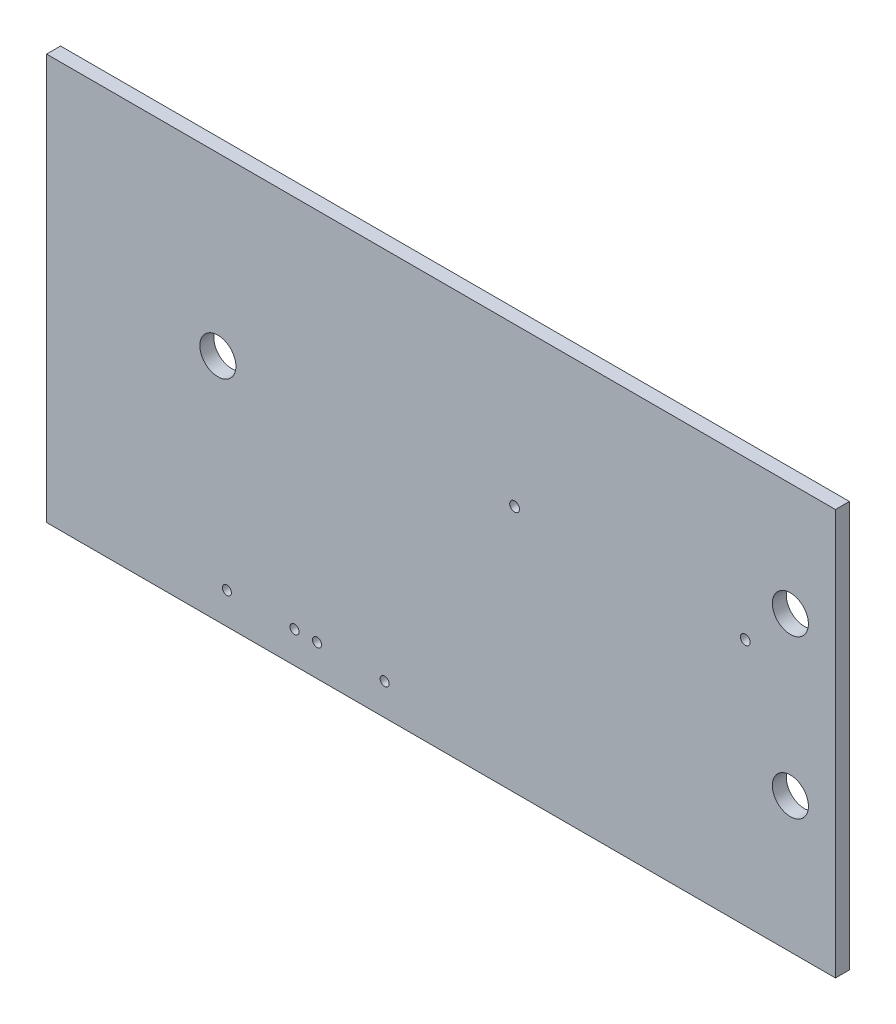
from build123d import *

# Parameters (mm, degrees)
SKETCH1_W                 = 88.9
SKETCH1_H                 = 45.72
BOARD_SHAPE_EXTRUDE_DEPTH = 1.5748
SKETCH2_R                 = 0.55
MMC_MOUNT_HOLE_CUT_DEPTH  = 1.5748
SKETCH4_R                 = 0.508
HFBR_ANCHOR_HOLES_DEPTH   = 1.5748
SKETCH5_R                 = 2.032
CUT_EXTRUDE3_DEPTH        = 1.5748


with BuildPart() as part:
    # Sketch1 → board shape -extrude (new body)
    with BuildSketch(Plane.XY):
        with Locations((44.45, -22.86)):
            Rectangle(SKETCH1_W, SKETCH1_H)
    extrude(amount=BOARD_SHAPE_EXTRUDE_DEPTH)

    # Sketch2 → mmc mount hole - cut (cut)
    with BuildSketch(Plane.XY.offset(1.5748)):
        with Locations((52.74, -17.78)):
            Circle(SKETCH2_R)
        with Locations((78.74, -17.78)):
            Circle(SKETCH2_R)
    extrude(amount=-MMC_MOUNT_HOLE_CUT_DEPTH, mode=Mode.SUBTRACT)

    # Sketch4 → HFBR anchor holes (cut)
    with BuildSketch(Plane.XY.offset(1.5748)):
        with Locations((20.32, -42.164)):
            Circle(SKETCH4_R)
        with Locations((27.94, -42.164)):
            Circle(SKETCH4_R)
        with Locations((30.48, -42.164)):
            Circle(SKETCH4_R)
        with Locations((38.1, -42.164)):
            Circle(SKETCH4_R)
    extrude(amount=-HFBR_ANCHOR_HOLES_DEPTH, mode=Mode.SUBTRACT)

    # Sketch5 → Cut-Extrude3 (cut)
    with BuildSketch(Plane.XY.offset(1.5748)):
        with Locations((83.82, -30.48)):
            Circle(SKETCH5_R)
        with Locations((83.82, -12.7)):
            Circle(SKETCH5_R)
        with Locations((19.304, -19.812)):
            Circle(SKETCH5_R)
    extrude(amount=-CUT_EXTRUDE3_DEPTH, mode=Mode.SUBTRACT)


solid = part.part
